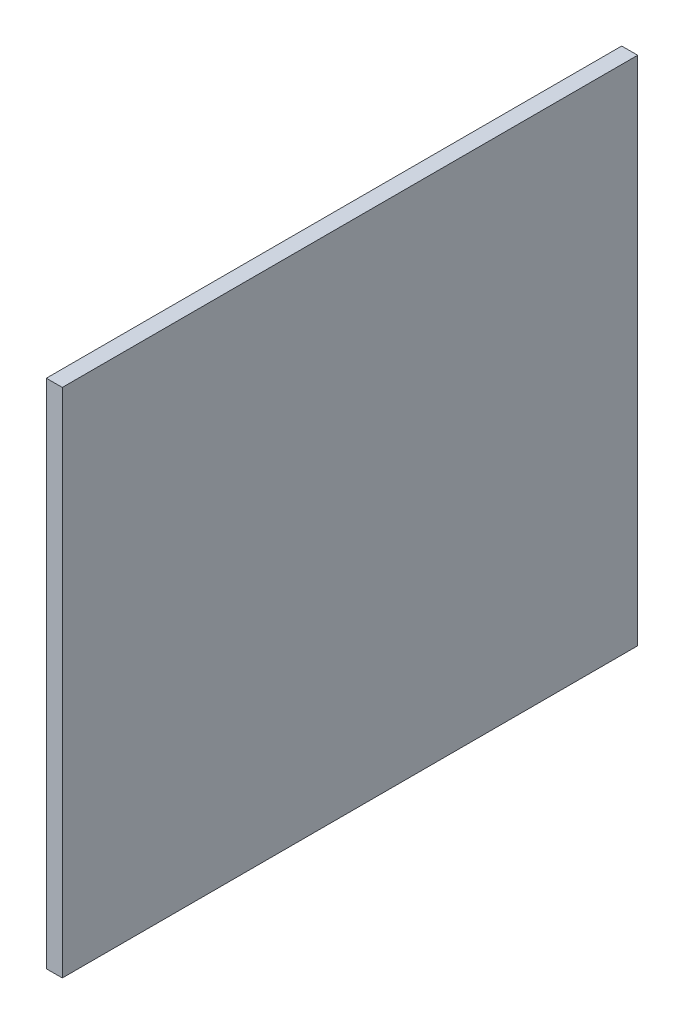
from build123d import *

# Parameters (mm, degrees)
SKETCH1_W           = 228.6
SKETCH1_H           = 203.2
BOSS_EXTRUDE1_DEPTH = 6.35


with BuildPart() as part:
    # Sketch1 → Boss-Extrude1 (new body)
    with BuildSketch(Plane(origin=(0, 0, 0), x_dir=(0, 0, -1), z_dir=(1, 0, 0))):
        Rectangle(SKETCH1_W, SKETCH1_H)
    extrude(amount=BOSS_EXTRUDE1_DEPTH)


solid = part.part
